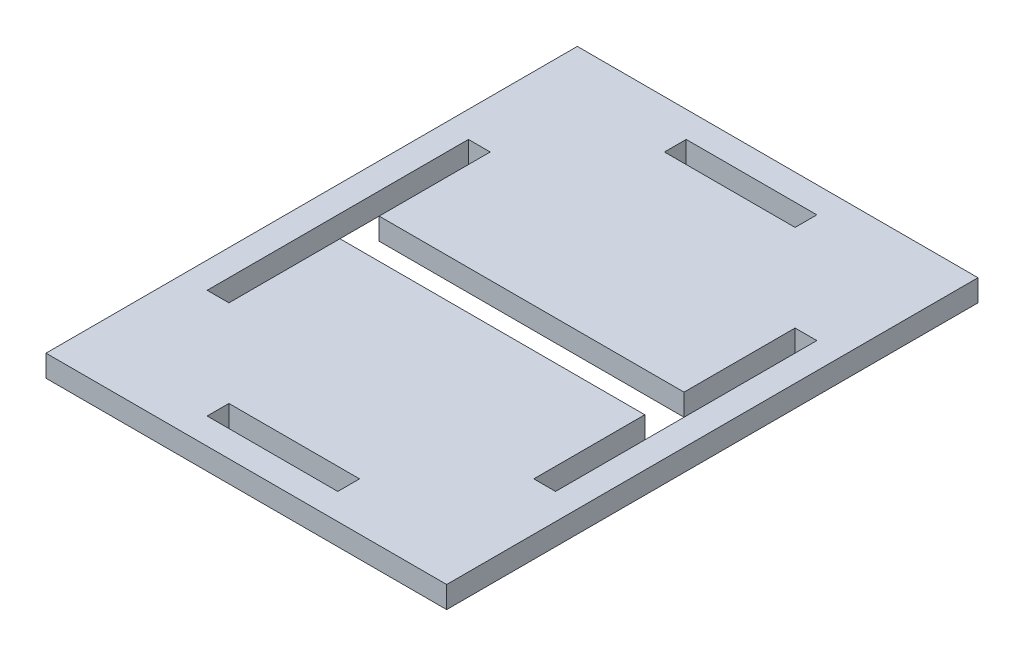
from build123d import *

# Parameters (mm, degrees)
SKETCH1_W           = 92
SKETCH1_H           = 122
BOSS_EXTRUDE1_DEPTH = 5
SKETCH2_W           = 5
SKETCH2_H           = 60
SKETCH2_W_2         = 30
SKETCH2_H_2         = 5
CUT_EXTRUDE1_DEPTH  = 6
SKETCH3_R           = 4.03
CUT_EXTRUDE2_DEPTH  = 5
SKETCH4_W           = 70
SKETCH4_H           = 9
CUT_EXTRUDE3_DEPTH  = 10


with BuildPart() as part:
    # Sketch1 → Boss-Extrude1 (new body)
    with BuildSketch(Plane(origin=(0, 0, 0), x_dir=(1, 0, 0), z_dir=(0, 1, 0))):
        Rectangle(SKETCH1_W, SKETCH1_H)
    extrude(amount=BOSS_EXTRUDE1_DEPTH)

    # Sketch2 → Cut-Extrude1 (cut, through all)
    with BuildSketch(Plane(origin=(0, 5, 0), x_dir=(1, 0, 0), z_dir=(0, 1, 0))):
        with Locations((-37.5, 0)):
            Rectangle(SKETCH2_W, SKETCH2_H)
        with Locations((37.5, 0)):
            Rectangle(SKETCH2_W, SKETCH2_H)
        with Locations((0, 52.5)):
            Rectangle(SKETCH2_W_2, SKETCH2_H_2)
        with Locations((0, -52.5)):
            Rectangle(SKETCH2_W_2, SKETCH2_H_2)
    extrude(amount=-CUT_EXTRUDE1_DEPTH, mode=Mode.SUBTRACT)

    # Sketch3 → Cut-Extrude2 (cut)
    with BuildSketch(Plane(origin=(0, 5, 0), x_dir=(1, 0, 0), z_dir=(0, 1, 0))):
        with Locations(Location((0, 0, 0), (0, 0, 270))):  # turned: the seam where the file's is
            Circle(SKETCH3_R)
        with Locations(Location((-20, 0, 0), (0, 0, 270))):  # turned: the seam where the file's is
            Circle(SKETCH3_R)
        with Locations(Location((20, 0, 0), (0, 0, 270))):  # turned: the seam where the file's is
            Circle(SKETCH3_R)
    extrude(amount=-CUT_EXTRUDE2_DEPTH, mode=Mode.SUBTRACT)

    # Sketch4 → Cut-Extrude3 (cut)
    with BuildSketch(Plane(origin=(0, 5, 0), x_dir=(1, 0, 0), z_dir=(0, 1, 0))):
        Rectangle(SKETCH4_W, SKETCH4_H)
    extrude(amount=-CUT_EXTRUDE3_DEPTH, mode=Mode.SUBTRACT)


solid = part.part
